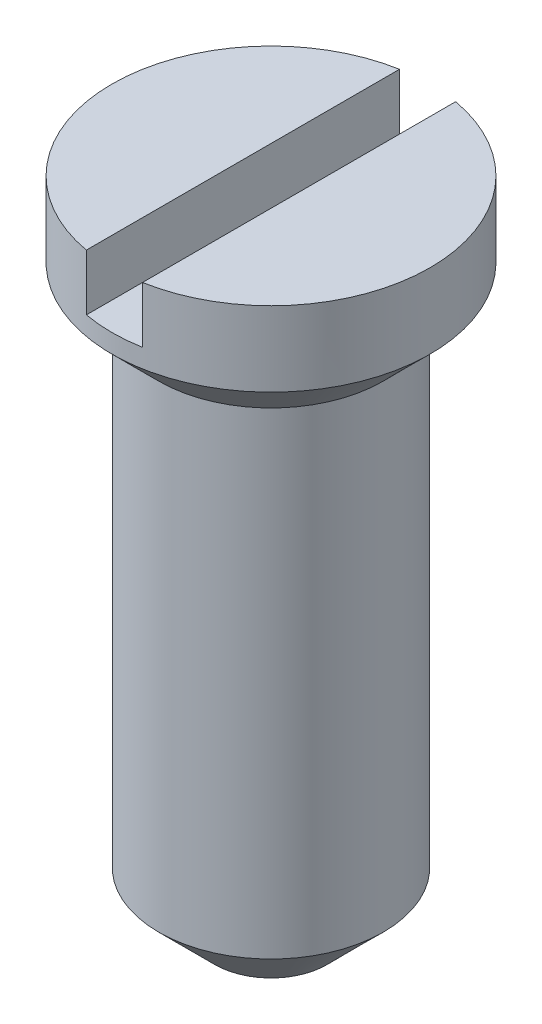
from build123d import *

# Parameters (mm, degrees)
SKETCH2_R           = 0.85
BOSS_EXTRUDE1_DEPTH = 3.5
SKETCH4_W           = 0.3
SKETCH4_H           = 1.9
CUT_EXTRUDE1_DEPTH  = 0.3
CHAMFER1_SIZE       = 0.3


with BuildPart() as part:
    # Sketch2 → Boss-Extrude1 (new body)
    with BuildSketch(Plane(origin=(0, 0, 0), x_dir=(1, 0, 0), z_dir=(0, 1, 0))):
        Circle(SKETCH2_R)
    extrude(amount=BOSS_EXTRUDE1_DEPTH)

    # Sketch3 → Cut-Revolve1 (revolve, cut)
    with BuildSketch(Plane.XY):
        Polygon((0.85, 3.1), (0.6, 2.85), (0.6, 0), (0.85, 0), align=None)
    revolve(axis=Axis((0, 0, 0), (0, 1, 0)), mode=Mode.SUBTRACT)

    # Sketch4 → Cut-Extrude1 (cut)
    with BuildSketch(Plane(origin=(0, 3.5, 0), x_dir=(1, 0, 0), z_dir=(0, 1, 0))):
        Rectangle(SKETCH4_W, SKETCH4_H)
    extrude(amount=-CUT_EXTRUDE1_DEPTH, mode=Mode.SUBTRACT)

    # Chamfer1
    chamfer1_edges = [part.edges().sort_by_distance(p)[0] for p in [
        (-0.6, 0, 0),
    ]]
    chamfer(chamfer1_edges, length=CHAMFER1_SIZE)


solid = part.part
